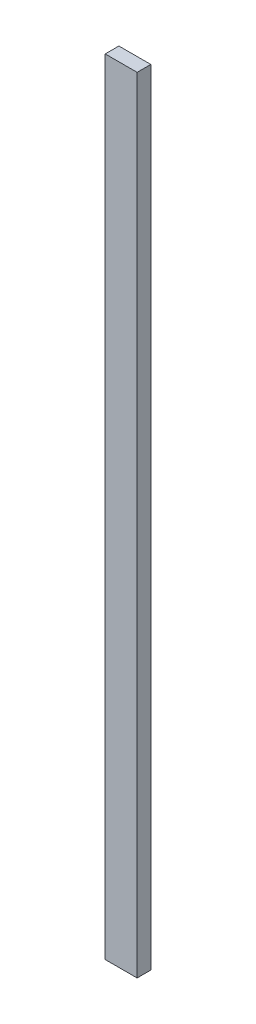
from build123d import *

# Parameters (mm, degrees)
SKETCH1_W           = 88.9
SKETCH1_H           = 38.1
BOSS_EXTRUDE1_DEPTH = 2184.4


with BuildPart() as part:
    # Sketch1 → Boss-Extrude1 (new body)
    with BuildSketch(Plane(origin=(0, 0, 0), x_dir=(1, 0, 0), z_dir=(0, 1, 0))):
        Rectangle(SKETCH1_W, SKETCH1_H)
    extrude(amount=BOSS_EXTRUDE1_DEPTH)


solid = part.part
